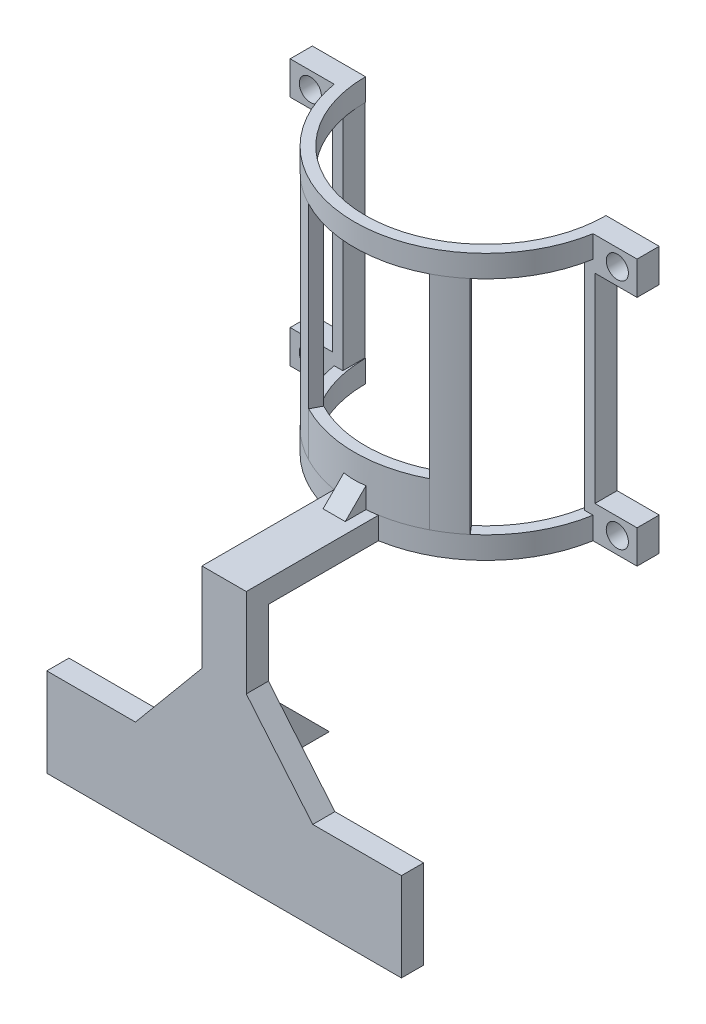
from build123d import *

# Parameters (mm, degrees)
EXTRUDE_1_DEPTH     = 20
EXTRUDE_2_REACH     = 218.11
EXTRUDE_7_DEPTH     = 20
SKETCH_13_R         = 10
CUT_EXTRUDE_1_DEPTH = 20
EXTRUDE_8_DEPTH     = 20
EXTRUDE_9_DEPTH     = 200
EXTRUDE_10_DEPTH    = 40
EXTRUDE_11_DEPTH    = 10
EXTRUDE_13_DEPTH    = 20
EXTRUDE_14_DEPTH    = 15


with BuildPart() as part:
    # 草图1 → 凸台-拉伸1 (new body)
    with BuildSketch(Plane(origin=(0, 0, 0), x_dir=(1, 0, 0), z_dir=(0, 1, 0))):
        with BuildLine():
            Line((-118.5, 0), (-108.5, 0))
            ThreePointArc((-108.5, 0), (0, -108.5), (108.5, 0))
            Line((108.5, 0), (118.5, 0))
            ThreePointArc((118.5, 0), (0, -118.5), (-118.5, 0))
        make_face()
    extrude(amount=EXTRUDE_1_DEPTH)

    # 草图3 → 凸台-拉伸2 (add, up to next)
    with BuildSketch(Plane.XY.offset(216.11), mode=Mode.PRIVATE) as extrude_2_sk1:
        Polygon((0, 0), (20, 0), (20, 20), (-20, 20), (-20, 0), align=None)
    extrude_2_tool1 = extrude(extrude_2_sk1.sketch, amount=-EXTRUDE_2_REACH, mode=Mode.PRIVATE) - part.part
    add(extrude_2_tool1.solids().sort_by_distance((0, 10, 216.11))[0])

    # 草图12 → 凸台-拉伸7 (add)
    with BuildSketch(Plane.XY):
        Polygon((-109, 0), (-156.5, 0), (-156.5, 30), (-118.5, 30), (-118.5, 210), (-156.5, 210), (-156.5, 240), (-109, 240), align=None)
        Polygon((156.5, 0), (109, 0), (109, 240), (156.5, 240), (156.5, 210), (118.5, 210), (118.5, 30), (156.5, 30), align=None)
    extrude(amount=EXTRUDE_7_DEPTH)

    # 草图13 → 切除-拉伸1 (cut)
    with BuildSketch(Plane(origin=(0, 0, 0), x_dir=(-1, 0, 0), z_dir=(0, 0, -1))):
        with Locations((138.306064525, 225)):
            Circle(SKETCH_13_R)
        with Locations((138.306064525, 15)):
            Circle(SKETCH_13_R)
        with Locations((-138.70464108, 225)):
            Circle(SKETCH_13_R)
        with Locations((-138.70464108, 15)):
            Circle(SKETCH_13_R)
    extrude(amount=-CUT_EXTRUDE_1_DEPTH, mode=Mode.SUBTRACT)

    # 草图14 → 凸台-拉伸8 (add)
    with BuildSketch(Plane(origin=(0, 240, 0), x_dir=(1, 0, 0), z_dir=(0, 1, 0))):
        with BuildLine():
            Line((-118.5, 0), (-108.5, 0))
            ThreePointArc((-108.5, 0), (0, -108.5), (108.5, 0))
            Line((108.5, 0), (118.5, 0))
            ThreePointArc((118.5, 0), (0, -118.5), (-118.5, 0))
        make_face()
    extrude(amount=-EXTRUDE_8_DEPTH)

    # 草图15 → 凸台-拉伸9 (add)
    with BuildSketch(Plane.XZ.offset(-220)):
        with BuildLine():
            Line((54.608292776, 105.167411113), (50, 96.292523074))
            ThreePointArc((50, 96.292523074), (60.372563146, 90.152113781), (70, 82.899034976))
            Line((70, 82.899034976), (76.451614759, 90.539497463))
            ThreePointArc((76.451614759, 90.539497463), (65.936855496, 98.461065578), (54.608292776, 105.167411113))
        make_face()
        with BuildLine():
            Line((-76.451614759, 90.539497463), (-70, 82.899034976))
            ThreePointArc((-70, 82.899034976), (-60.372563146, 90.152113781), (-50, 96.292523074))
            Line((-50, 96.292523074), (-54.608292776, 105.167411113))
            ThreePointArc((-54.608292776, 105.167411113), (-65.936855496, 98.461065578), (-76.451614759, 90.539497463))
        make_face()
    extrude(amount=EXTRUDE_9_DEPTH)

    # 草图16 → 凸台-拉伸10 (add)
    with BuildSketch(Plane(origin=(0, 20, 0), x_dir=(1, 0, 0), z_dir=(0, 1, 0))):
        with BuildLine():
            Line((-50, -96.292523074), (-54.608292776, -105.167411113))
            ThreePointArc((-54.608292776, -105.167411113), (0, -118.499993567), (54.608292776, -105.167411113))
            Line((54.608292776, -105.167411113), (50, -96.292523074))
            ThreePointArc((50, -96.292523074), (0, -108.5), (-50, -96.292523074))
        make_face()
    extrude(amount=EXTRUDE_10_DEPTH)

    # 草图17 → 凸台-拉伸11 (add, symmetric)
    with BuildSketch(Plane(origin=(0, 0, 0), x_dir=(0, 0, -1), z_dir=(1, 0, 0))):
        Polygon((-136.800037114, 20), (-116.800037114, 20), (-116.800037114, 40), align=None)
    extrude(amount=EXTRUDE_11_DEPTH, both=True)

    # 草图18 → 凸台-拉伸13 (add)
    with BuildSketch(Plane.XY.offset(216.11)):
        Polygon((-20, 20), (20, 20), (20, 0), (20, -60), (80, -132), (160, -132), (160, -212), (-160, -212), (-160, -132), (-80, -132), (-20, -60), (-20, 0), align=None)
    extrude(amount=EXTRUDE_13_DEPTH)

    # 草图22 → 凸台-拉伸14 (add, symmetric)
    with BuildSketch(Plane(origin=(0, 0, 0), x_dir=(0, 0, -1), z_dir=(1, 0, 0))):
        Polygon((-216.11, -72), (-156.11, -132), (-216.11, -132), align=None)
    extrude(amount=EXTRUDE_14_DEPTH, both=True)


solid = part.part
